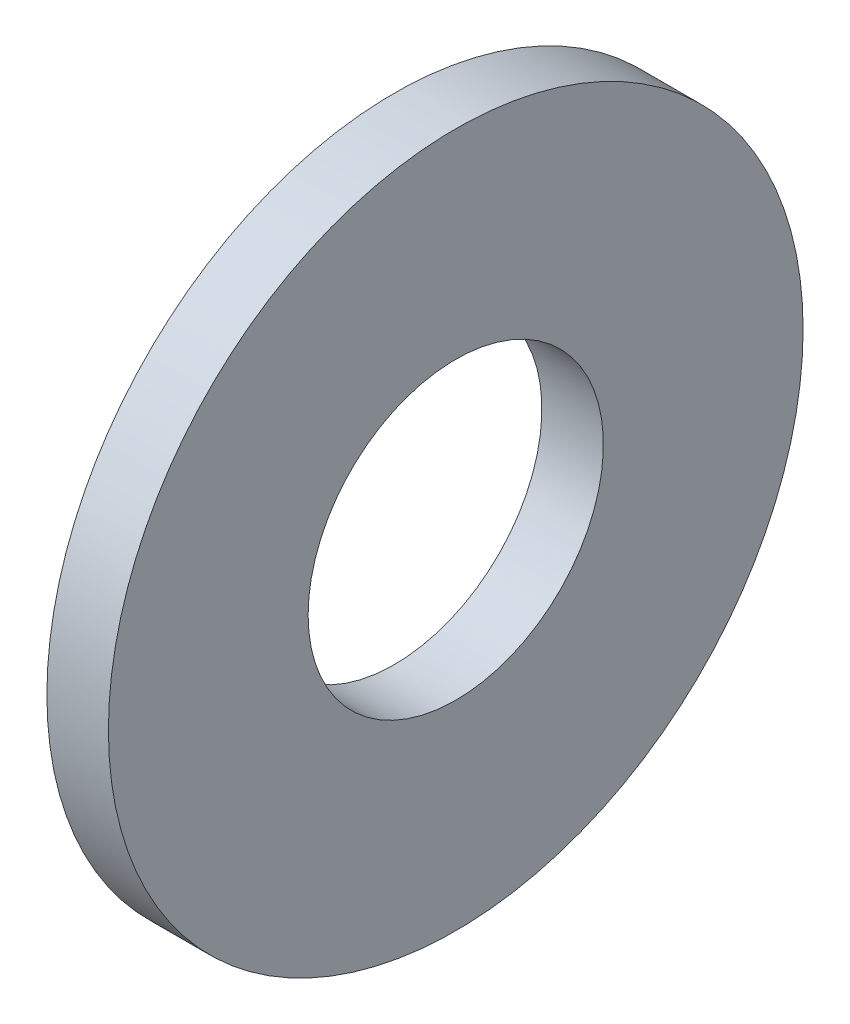
from build123d import *

# Parameters (mm, degrees)
SKETCH1_W = 1.651
SKETCH1_H = 5.3594


with BuildPart() as part:
    # Sketch1 → Base-Revolve (revolve)
    with BuildSketch(Plane.XY):
        with Locations((-0.8255, 6.6421)):
            Rectangle(SKETCH1_W, SKETCH1_H)
    revolve(axis=Axis((-34.925, 0, 0), (1, 0, 0)))


solid = part.part
